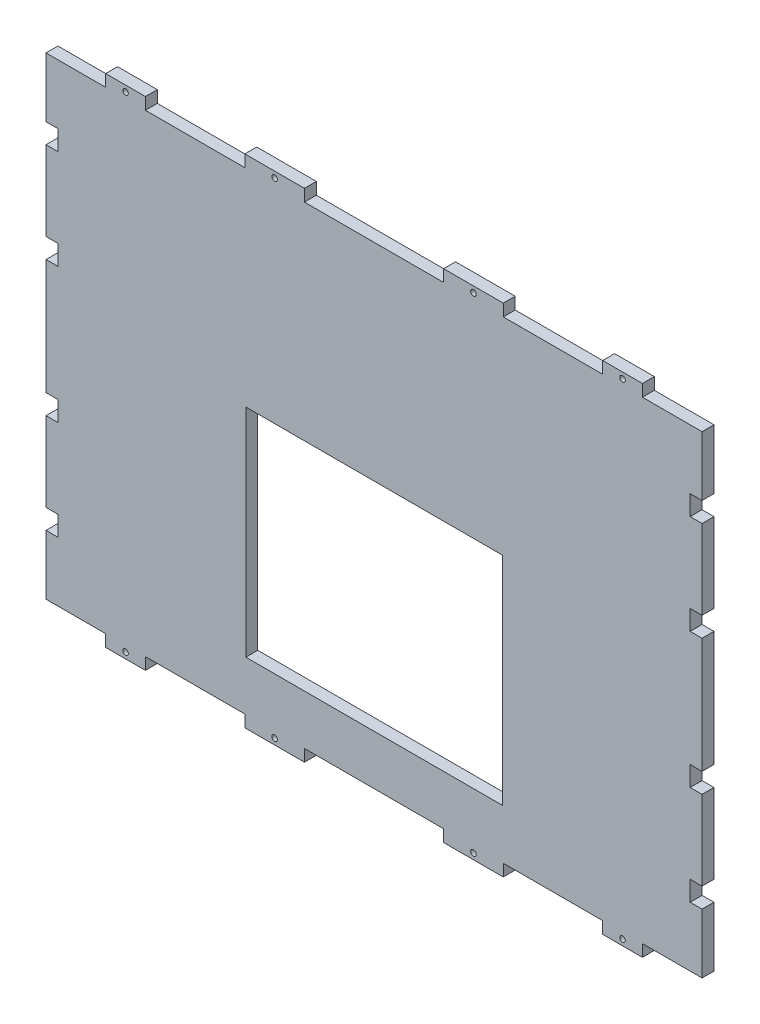
from build123d import *

# Parameters (mm, degrees)
ESQUISSE1_W             = 330
ESQUISSE1_H             = 238
BOSS_EXTRU_1_DEPTH      = 6
ESQUISSE2_W             = 129
ESQUISSE2_H             = 109
ENL_V_MAT_EXTRU_1_DEPTH = 6
ESQUISSE3_W             = 20
ESQUISSE3_H             = 6
ESQUISSE3_W_2           = 30
BOSS_EXTRU_4_DEPTH      = 6
ESQUISSE4_W             = 6
ESQUISSE4_H             = 10
ENL_V_MAT_EXTRU_3_DEPTH = 6
ESQUISSE5_R             = 1.4
ENL_V_MAT_EXTRU_4_DEPTH = 6


with BuildPart() as part:
    # Esquisse1 → Boss.-Extru.1 (new body)
    with BuildSketch(Plane.XY):
        Rectangle(ESQUISSE1_W, ESQUISSE1_H)
    extrude(amount=BOSS_EXTRU_1_DEPTH)

    # Esquisse2 → Enlèv. mat.-Extru.1 (cut)
    with BuildSketch(Plane.XY.offset(6)):
        with Locations((0, -39.5)):
            Rectangle(ESQUISSE2_W, ESQUISSE2_H)
    extrude(amount=-ENL_V_MAT_EXTRU_1_DEPTH, mode=Mode.SUBTRACT)

    # Esquisse3 → Boss.-Extru.4 (add)
    with BuildSketch(Plane.XY.offset(6)):
        with Locations((-125, 122)):
            Rectangle(ESQUISSE3_W, ESQUISSE3_H)
        with Locations((-50, 122)):
            Rectangle(ESQUISSE3_W_2, ESQUISSE3_H)
        with Locations((50, 122)):
            Rectangle(ESQUISSE3_W_2, ESQUISSE3_H)
        with Locations((125, 122)):
            Rectangle(ESQUISSE3_W, ESQUISSE3_H)
        with Locations((125, -122)):
            Rectangle(ESQUISSE3_W, ESQUISSE3_H)
        with Locations((50, -122)):
            Rectangle(ESQUISSE3_W_2, ESQUISSE3_H)
        with Locations((-50, -122)):
            Rectangle(ESQUISSE3_W_2, ESQUISSE3_H)
        with Locations((-125, -122)):
            Rectangle(ESQUISSE3_W, ESQUISSE3_H)
    extrude(amount=-BOSS_EXTRU_4_DEPTH)

    # Esquisse4 → Enlèv. mat.-Extru.3 (cut)
    with BuildSketch(Plane.XY.offset(6)):
        with Locations((-162, 84)):
            Rectangle(ESQUISSE4_W, ESQUISSE4_H)
        with Locations((-162, 34)):
            Rectangle(ESQUISSE4_W, ESQUISSE4_H)
        with Locations((-162, -84)):
            Rectangle(ESQUISSE4_W, ESQUISSE4_H)
        with Locations((-162, -34)):
            Rectangle(ESQUISSE4_W, ESQUISSE4_H)
        with Locations((162, -84)):
            Rectangle(ESQUISSE4_W, ESQUISSE4_H)
        with Locations((162, -34)):
            Rectangle(ESQUISSE4_W, ESQUISSE4_H)
        with Locations((162, 34)):
            Rectangle(ESQUISSE4_W, ESQUISSE4_H)
        with Locations((162, 84)):
            Rectangle(ESQUISSE4_W, ESQUISSE4_H)
    extrude(amount=-ENL_V_MAT_EXTRU_3_DEPTH, mode=Mode.SUBTRACT)

    # Esquisse5 → Enlèv. mat.-Extru.4 (cut)
    with BuildSketch(Plane.XY.offset(6)):
        with Locations((-125, 122)):
            Circle(ESQUISSE5_R)
        with Locations((-50, 122)):
            Circle(ESQUISSE5_R)
        with Locations((50, 122)):
            Circle(ESQUISSE5_R)
        with Locations((125, 122)):
            Circle(ESQUISSE5_R)
        with Locations((125, -122)):
            Circle(ESQUISSE5_R)
        with Locations((50, -122)):
            Circle(ESQUISSE5_R)
        with Locations((-50, -122)):
            Circle(ESQUISSE5_R)
        with Locations((-125, -122)):
            Circle(ESQUISSE5_R)
    extrude(amount=-ENL_V_MAT_EXTRU_4_DEPTH, mode=Mode.SUBTRACT)


solid = part.part
